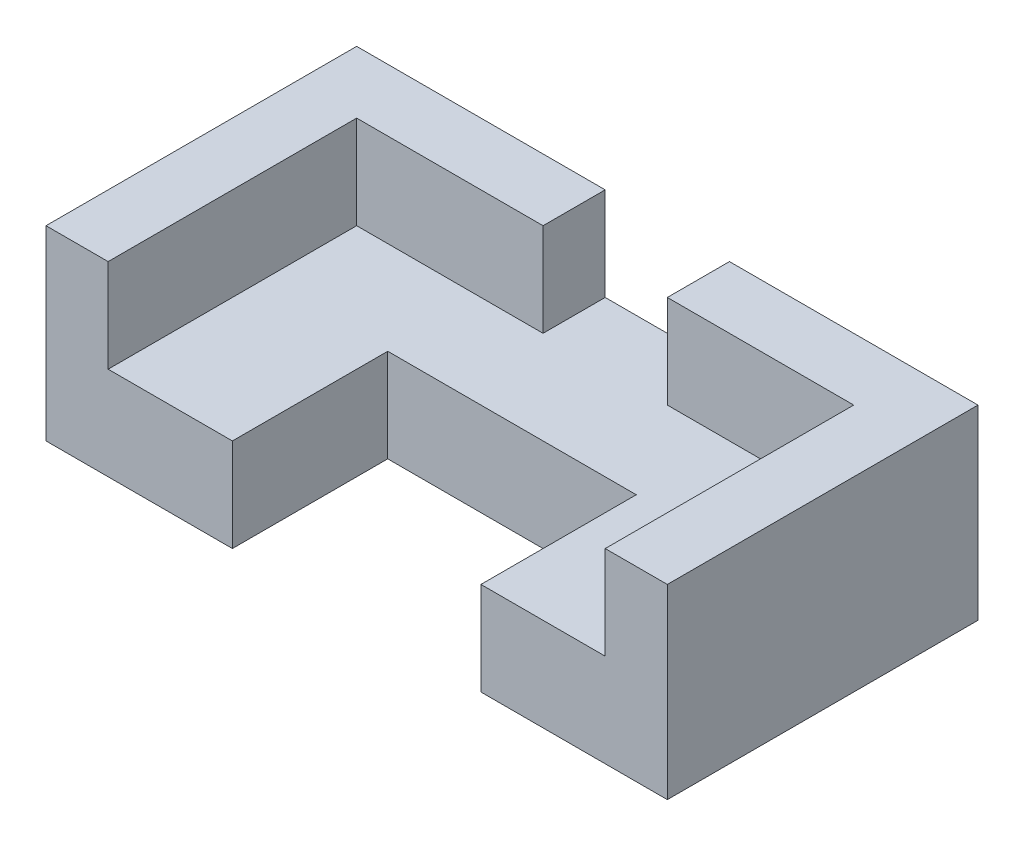
from build123d import *

# Parameters (mm, degrees)
BOSS_EXTRUDE1_DEPTH = 15
BOSS_EXTRUDE2_DEPTH = 15
SKETCH3_W           = 20
SKETCH3_H           = 10
CUT_EXTRUDE1_DEPTH  = 15


with BuildPart() as part:
    # Sketch1 → Boss-Extrude1 (new body)
    with BuildSketch(Plane(origin=(0, 0, 0), x_dir=(1, 0, 0), z_dir=(0, 1, 0))):
        Polygon((0, 0), (30, 0), (30, 25), (70, 25), (70, 0), (100, 0), (100, 50), (0, 50), align=None)
    extrude(amount=BOSS_EXTRUDE1_DEPTH)

    # Sketch2 → Boss-Extrude2 (add)
    with BuildSketch(Plane(origin=(0, 15, 0), x_dir=(1, 0, 0), z_dir=(0, 1, 0))):
        Polygon((0, 0), (10, 0), (10, 40), (90, 40), (90, 0), (100, 0), (100, 50), (0, 50), align=None)
    extrude(amount=BOSS_EXTRUDE2_DEPTH)

    # Sketch3 → Cut-Extrude1 (cut)
    with BuildSketch(Plane(origin=(0, 30, 0), x_dir=(1, 0, 0), z_dir=(0, 1, 0))):
        with Locations((50, 45)):
            Rectangle(SKETCH3_W, SKETCH3_H)
    extrude(amount=-CUT_EXTRUDE1_DEPTH, mode=Mode.SUBTRACT)


solid = part.part
